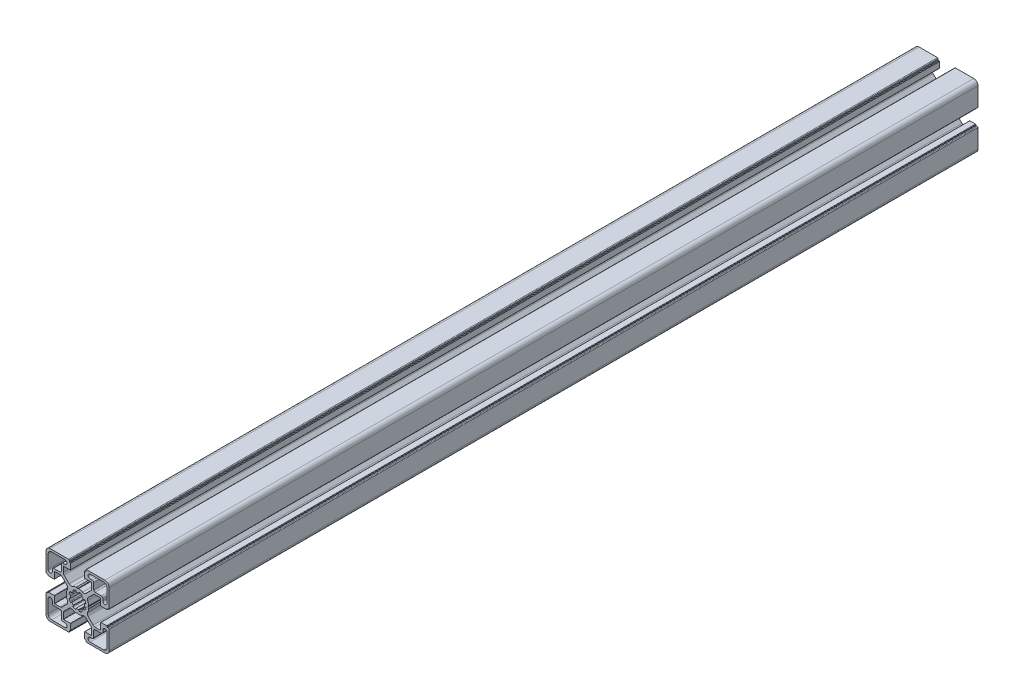
from build123d import *

# Parameters (mm, degrees)
BASE_EXTRUDE_DEPTH = 620


with BuildPart() as part:
    # Sketch1 → Base-Extrude (new body)
    with BuildSketch(Plane.XY):
        with BuildLine():
            Line((7.973976585, 0.792591518), (7.540060475, 0.046829556))
            ThreePointArc((7.540060475, 0.046829556), (7.534295984, 0.023675638), (7.531329941, 0))
            ThreePointArc((7.531329941, 0), (7.534295984, -0.023675638), (7.540060475, -0.046829556))
            Line((7.540060475, -0.046829556), (7.973976585, -0.792591518))
            ThreePointArc((7.973976585, -0.792591518), (7.996666421, -0.851255641), (8.000014047, -0.914065683))
            ThreePointArc((8.000014047, -0.914065683), (7.719730741, -2.298395946), (7.20036345, -3.611859543))
            ThreePointArc((7.20036345, -3.611859543), (7.018857217, -4.793954471), (7.563483933, -5.85869607))
            Line((7.563483933, -5.85869607), (11.129779889, -9.424988026))
            ThreePointArc((11.129779889, -9.424988026), (11.760624613, -9.84650461), (12.504756513, -9.99452154))
            Line((12.504756513, -9.99452154), (16.316902451, -9.99452154))
            ThreePointArc((16.316902451, -9.99452154), (16.458324055, -9.935942793), (16.516902802, -9.794521189))
            Line((16.516902802, -9.794521189), (16.516902802, -5.200014226))
            ThreePointArc((16.516902802, -5.200014226), (16.575481548, -5.058592621), (16.716903152, -5.000013875))
            Line((16.716903152, -5.000013875), (20.719599904, -5.000013875))
            ThreePointArc((20.719599904, -5.000013875), (20.931731427, -5.087881629), (21.01959918, -5.300013151))
            Line((21.01959918, -5.300013151), (21.01959918, -5.500004099))
            ThreePointArc((21.01959918, -5.500004099), (21.10746708, -5.712135974), (21.319598956, -5.800003874))
            Line((21.319598956, -5.800003874), (21.999979514, -5.800003874))
            ThreePointArc((21.999979514, -5.800003874), (22.35353264, -5.946450374), (22.49997914, -6.300003501))
            Line((22.49997914, -6.300003501), (22.49997914, -19.500016116))
            ThreePointArc((22.49997914, -19.500016116), (21.62130014, -21.621334875), (19.499981381, -22.500013875))
            Line((19.499981381, -22.500013875), (6.375709012, -22.500013875))
            ThreePointArc((6.375709012, -22.500013875), (6.022155886, -22.353567375), (5.875709386, -22.000014249))
            Line((5.875709386, -22.000014249), (5.875709386, -21.30001315))
            ThreePointArc((5.875709386, -21.30001315), (5.787841632, -21.087881628), (5.57571011, -21.000013874))
            Line((5.57571011, -21.000013874), (5.299998776, -21.000013874))
            ThreePointArc((5.299998776, -21.000013874), (5.087867607, -20.912146267), (5, -20.700015099))
            Line((5, -20.700015099), (5, -16.666812433))
            ThreePointArc((5, -16.666812433), (5.058578893, -16.525390475), (5.200000851, -16.466811582))
            Line((5.200000851, -16.466811582), (9.905385218, -16.466811582))
            ThreePointArc((9.905385218, -16.466811582), (10.046806822, -16.408232835), (10.105385569, -16.266811231))
            Line((10.105385569, -16.266811231), (10.105385569, -12.471582956))
            ThreePointArc((10.105385569, -12.471582956), (9.953144588, -11.706215861), (9.519598955, -11.057368968))
            Line((9.519598955, -11.057368968), (5.944897989, -7.482668002))
            ThreePointArc((5.944897989, -7.482668002), (4.854601835, -6.967833724), (3.666499237, -7.173289937))
            ThreePointArc((3.666499237, -7.173289937), (2.309136684, -7.713848333), (0.876396038, -8.000013875))
            ThreePointArc((0.876396038, -8.000013875), (0.81356491, -7.997088573), (0.754749577, -7.974793627))
            Line((0.754749577, -7.974793627), (0.11262846, -7.606936933))
            ThreePointArc((0.11262846, -7.606936933), (0.062963903, -7.559088739), (0, -7.530953975))
            ThreePointArc((0, -7.530953975), (-0.062963903, -7.559088739), (-0.11262846, -7.606936933))
            Line((-0.11262846, -7.606936933), (-0.754749577, -7.974793627))
            ThreePointArc((-0.754749577, -7.974793627), (-0.81356491, -7.997088573), (-0.876396038, -8.000013875))
            ThreePointArc((-0.876396038, -8.000013875), (-2.309136684, -7.713848333), (-3.666499237, -7.173289937))
            ThreePointArc((-3.666499237, -7.173289937), (-4.854601835, -6.967833724), (-5.944897989, -7.482668002))
            Line((-5.944897989, -7.482668002), (-9.519598955, -11.057368968))
            ThreePointArc((-9.519598955, -11.057368968), (-9.953144588, -11.706215861), (-10.105385569, -12.471582956))
            Line((-10.105385569, -12.471582956), (-10.105385569, -16.266811231))
            ThreePointArc((-10.105385569, -16.266811231), (-10.046806822, -16.408232835), (-9.905385218, -16.466811582))
            Line((-9.905385218, -16.466811582), (-5.200000851, -16.466811582))
            ThreePointArc((-5.200000851, -16.466811582), (-5.058578893, -16.525390475), (-5, -16.666812433))
            Line((-5, -16.666812433), (-5, -20.700015099))
            ThreePointArc((-5, -20.700015099), (-5.087867607, -20.912146267), (-5.299998776, -21.000013874))
            Line((-5.299998776, -21.000013874), (-5.57571011, -21.000013874))
            ThreePointArc((-5.57571011, -21.000013874), (-5.787841632, -21.087881628), (-5.875709386, -21.30001315))
            Line((-5.875709386, -21.30001315), (-5.875709386, -22.000014249))
            ThreePointArc((-5.875709386, -22.000014249), (-6.022155886, -22.353567375), (-6.375709012, -22.500013875))
            Line((-6.375709012, -22.500013875), (-19.499981381, -22.500013875))
            ThreePointArc((-19.499981381, -22.500013875), (-21.62130014, -21.621334875), (-22.49997914, -19.500016116))
            Line((-22.49997914, -19.500016116), (-22.49997914, -6.300003501))
            ThreePointArc((-22.49997914, -6.300003501), (-22.35353264, -5.946450374), (-21.999979514, -5.800003874))
            Line((-21.999979514, -5.800003874), (-21.319598956, -5.800003874))
            ThreePointArc((-21.319598956, -5.800003874), (-21.10746708, -5.712135974), (-21.01959918, -5.500004099))
            Line((-21.01959918, -5.500004099), (-21.01959918, -5.300013151))
            ThreePointArc((-21.01959918, -5.300013151), (-20.931731427, -5.087881629), (-20.719599904, -5.000013875))
            Line((-20.719599904, -5.000013875), (-16.716903152, -5.000013875))
            ThreePointArc((-16.716903152, -5.000013875), (-16.575481548, -5.058592621), (-16.516902802, -5.200014226))
            Line((-16.516902802, -5.200014226), (-16.516902802, -9.794521189))
            ThreePointArc((-16.516902802, -9.794521189), (-16.458324055, -9.935942793), (-16.316902451, -9.99452154))
            Line((-16.316902451, -9.99452154), (-12.504756513, -9.99452154))
            ThreePointArc((-12.504756513, -9.99452154), (-11.760624613, -9.84650461), (-11.129779889, -9.424988026))
            Line((-11.129779889, -9.424988026), (-7.563483933, -5.85869607))
            ThreePointArc((-7.563483933, -5.85869607), (-7.018857217, -4.793954471), (-7.20036345, -3.611859543))
            ThreePointArc((-7.20036345, -3.611859543), (-7.719730741, -2.298395946), (-8.000014047, -0.914065683))
            ThreePointArc((-8.000014047, -0.914065683), (-7.996666421, -0.851255641), (-7.973976585, -0.792591518))
            Line((-7.973976585, -0.792591518), (-7.540060475, -0.046829556))
            ThreePointArc((-7.540060475, -0.046829556), (-7.534295984, -0.023675638), (-7.531329941, 0))
            ThreePointArc((-7.531329941, 0), (-7.534295984, 0.023675638), (-7.540060475, 0.046829556))
            Line((-7.540060475, 0.046829556), (-7.973976585, 0.792591518))
            ThreePointArc((-7.973976585, 0.792591518), (-7.996666421, 0.851255641), (-8.000014047, 0.914065683))
            ThreePointArc((-8.000014047, 0.914065683), (-7.719730741, 2.298395946), (-7.20036345, 3.611859543))
            ThreePointArc((-7.20036345, 3.611859543), (-7.018857217, 4.793954471), (-7.563483933, 5.85869607))
            Line((-7.563483933, 5.85869607), (-11.129779889, 9.424988026))
            ThreePointArc((-11.129779889, 9.424988026), (-11.760624613, 9.84650461), (-12.504756513, 9.99452154))
            Line((-12.504756513, 9.99452154), (-16.316902451, 9.99452154))
            ThreePointArc((-16.316902451, 9.99452154), (-16.458324055, 9.935942793), (-16.516902802, 9.794521189))
            Line((-16.516902802, 9.794521189), (-16.516902802, 5.200014226))
            ThreePointArc((-16.516902802, 5.200014226), (-16.575481548, 5.058592621), (-16.716903152, 5.000013875))
            Line((-16.716903152, 5.000013875), (-20.719599904, 5.000013875))
            ThreePointArc((-20.719599904, 5.000013875), (-20.931731427, 5.087881629), (-21.01959918, 5.300013151))
            Line((-21.01959918, 5.300013151), (-21.01959918, 5.500004099))
            ThreePointArc((-21.01959918, 5.500004099), (-21.10746708, 5.712135974), (-21.319598956, 5.800003874))
            Line((-21.319598956, 5.800003874), (-21.999979514, 5.800003874))
            ThreePointArc((-21.999979514, 5.800003874), (-22.35353264, 5.946450374), (-22.49997914, 6.300003501))
            Line((-22.49997914, 6.300003501), (-22.49997914, 19.500016116))
            ThreePointArc((-22.49997914, 19.500016116), (-21.62130014, 21.621334875), (-19.499981381, 22.500013875))
            Line((-19.499981381, 22.500013875), (-6.375709012, 22.500013875))
            ThreePointArc((-6.375709012, 22.500013875), (-6.022155886, 22.353567375), (-5.875709386, 22.000014249))
            Line((-5.875709386, 22.000014249), (-5.875709386, 21.30001315))
            ThreePointArc((-5.875709386, 21.30001315), (-5.787841632, 21.087881628), (-5.57571011, 21.000013874))
            Line((-5.57571011, 21.000013874), (-5.299998776, 21.000013874))
            ThreePointArc((-5.299998776, 21.000013874), (-5.087867607, 20.912146267), (-5, 20.700015099))
            Line((-5, 20.700015099), (-5, 16.666812433))
            ThreePointArc((-5, 16.666812433), (-5.058578893, 16.525390475), (-5.200000851, 16.466811582))
            Line((-5.200000851, 16.466811582), (-9.905385218, 16.466811582))
            ThreePointArc((-9.905385218, 16.466811582), (-10.046806822, 16.408232835), (-10.105385569, 16.266811231))
            Line((-10.105385569, 16.266811231), (-10.105385569, 12.471582956))
            ThreePointArc((-10.105385569, 12.471582956), (-9.953144588, 11.706215861), (-9.519598955, 11.057368968))
            Line((-9.519598955, 11.057368968), (-5.944897989, 7.482668002))
            ThreePointArc((-5.944897989, 7.482668002), (-4.854601835, 6.967833724), (-3.666499237, 7.173289937))
            ThreePointArc((-3.666499237, 7.173289937), (-2.309136684, 7.713848333), (-0.876396038, 8.000013875))
            ThreePointArc((-0.876396038, 8.000013875), (-0.81356491, 7.997088573), (-0.754749577, 7.974793627))
            Line((-0.754749577, 7.974793627), (-0.11262846, 7.606936933))
            ThreePointArc((-0.11262846, 7.606936933), (-0.062963903, 7.559088739), (0, 7.530953975))
            ThreePointArc((0, 7.530953975), (0.062963903, 7.559088739), (0.11262846, 7.606936933))
            Line((0.11262846, 7.606936933), (0.754749577, 7.974793627))
            ThreePointArc((0.754749577, 7.974793627), (0.81356491, 7.997088573), (0.876396038, 8.000013875))
            ThreePointArc((0.876396038, 8.000013875), (2.309136684, 7.713848333), (3.666499237, 7.173289937))
            ThreePointArc((3.666499237, 7.173289937), (4.854601835, 6.967833724), (5.944897989, 7.482668002))
            Line((5.944897989, 7.482668002), (9.519598955, 11.057368968))
            ThreePointArc((9.519598955, 11.057368968), (9.953144588, 11.706215861), (10.105385569, 12.471582956))
            Line((10.105385569, 12.471582956), (10.105385569, 16.266811231))
            ThreePointArc((10.105385569, 16.266811231), (10.046806822, 16.408232835), (9.905385218, 16.466811582))
            Line((9.905385218, 16.466811582), (5.200000851, 16.466811582))
            ThreePointArc((5.200000851, 16.466811582), (5.058578893, 16.525390475), (5, 16.666812433))
            Line((5, 16.666812433), (5, 20.700015099))
            ThreePointArc((5, 20.700015099), (5.087867607, 20.912146267), (5.299998776, 21.000013874))
            Line((5.299998776, 21.000013874), (5.57571011, 21.000013874))
            ThreePointArc((5.57571011, 21.000013874), (5.787841632, 21.087881628), (5.875709386, 21.30001315))
            Line((5.875709386, 21.30001315), (5.875709386, 22.000014249))
            ThreePointArc((5.875709386, 22.000014249), (6.022155886, 22.353567375), (6.375709012, 22.500013875))
            Line((6.375709012, 22.500013875), (19.499981381, 22.500013875))
            ThreePointArc((19.499981381, 22.500013875), (21.62130014, 21.621334875), (22.49997914, 19.500016116))
            Line((22.49997914, 19.500016116), (22.49997914, 6.300003501))
            ThreePointArc((22.49997914, 6.300003501), (22.35353264, 5.946450374), (21.999979514, 5.800003874))
            Line((21.999979514, 5.800003874), (21.319598956, 5.800003874))
            ThreePointArc((21.319598956, 5.800003874), (21.10746708, 5.712135974), (21.01959918, 5.500004099))
            Line((21.01959918, 5.500004099), (21.01959918, 5.300013151))
            ThreePointArc((21.01959918, 5.300013151), (20.931731427, 5.087881629), (20.719599904, 5.000013875))
            Line((20.719599904, 5.000013875), (16.716903152, 5.000013875))
            ThreePointArc((16.716903152, 5.000013875), (16.575481548, 5.058592621), (16.516902802, 5.200014226))
            Line((16.516902802, 5.200014226), (16.516902802, 9.794521189))
            ThreePointArc((16.516902802, 9.794521189), (16.458324055, 9.935942793), (16.316902451, 9.99452154))
            Line((16.316902451, 9.99452154), (12.504756513, 9.99452154))
            ThreePointArc((12.504756513, 9.99452154), (11.760624613, 9.84650461), (11.129779889, 9.424988026))
            Line((11.129779889, 9.424988026), (7.563483933, 5.85869607))
            ThreePointArc((7.563483933, 5.85869607), (7.018857217, 4.793954471), (7.20036345, 3.611859543))
            ThreePointArc((7.20036345, 3.611859543), (7.719730741, 2.298395946), (8.000014047, 0.914065683))
            ThreePointArc((8.000014047, 0.914065683), (7.996666421, 0.851255641), (7.973976585, 0.792591518))
        make_face()
        with BuildLine():
            Line((10.549978885, 18.000013874), (8.999979138, 18.000013874))
            ThreePointArc((8.999979138, 18.000013874), (7.499979138, 19.500013874), (8.999979138, 21.000013874))
            Line((8.999979138, 21.000013874), (18.499981006, 21.000013874))
            ThreePointArc((18.499981006, 21.000013874), (20.267746638, 20.267781374), (20.999979138, 18.500015742))
            Line((20.999979138, 18.500015742), (20.999979138, 9.000204874))
            ThreePointArc((20.999979138, 9.000204874), (19.499979138, 7.500204874), (17.999979138, 9.000204874))
            Line((17.999979138, 9.000204874), (17.999979138, 10.550013621))
            ThreePointArc((17.999979138, 10.550013621), (17.707086138, 11.257119874), (16.999979885, 11.550012874))
            Line((16.999979885, 11.550012874), (12.549977391, 11.550012874))
            ThreePointArc((12.549977391, 11.550012874), (11.842871138, 11.842905874), (11.549978138, 12.550012127))
            Line((11.549978138, 12.550012127), (11.549978138, 17.000014621))
            ThreePointArc((11.549978138, 17.000014621), (11.257085138, 17.707120874), (10.549978885, 18.000013874))
        make_face(mode=Mode.SUBTRACT)
        with BuildLine():
            Line((-0.867388737, 4.924188946), (-0.96752168, 5.481112935))
            ThreePointArc((-0.96752168, 5.481112935), (-1.187855719, 5.829589164), (-1.595071417, 5.894072848))
            ThreePointArc((-1.595071417, 5.894072848), (-2.338895973, 5.643477696), (-3.04438497, 5.299445466))
            ThreePointArc((-3.04438497, 5.299445466), (-3.284615367, 4.964275075), (-3.191311906, 4.562598216))
            Line((-3.191311906, 4.562598216), (-2.864000421, 4.09847552))
            ThreePointArc((-2.864000421, 4.09847552), (-3.53013295, 3.540926624), (-4.08971289, 2.876499344))
            Line((-4.08971289, 2.876499344), (-4.566777651, 3.208162503))
            ThreePointArc((-4.566777651, 3.208162503), (-4.968960845, 3.298770682), (-5.302497889, 3.056460542))
            ThreePointArc((-5.302497889, 3.056460542), (-5.651259984, 2.353310881), (-5.906847665, 1.611199444))
            ThreePointArc((-5.906847665, 1.611199444), (-5.839752063, 1.204293023), (-5.489730697, 0.98621116))
            Line((-5.489730697, 0.98621116), (-4.920545766, 0.887822825))
            ThreePointArc((-4.920545766, 0.887822825), (-4.980096828, 0.445685524), (-5, 0))
            ThreePointArc((-5, 0), (-4.980096828, -0.445685524), (-4.920545766, -0.887822825))
            Line((-4.920545766, -0.887822825), (-5.489730697, -0.98621116))
            ThreePointArc((-5.489730697, -0.98621116), (-5.839752063, -1.204293023), (-5.906847665, -1.611199444))
            ThreePointArc((-5.906847665, -1.611199444), (-5.651259984, -2.353310881), (-5.302497889, -3.056460542))
            ThreePointArc((-5.302497889, -3.056460542), (-4.968960845, -3.298770682), (-4.566777651, -3.208162503))
            Line((-4.566777651, -3.208162503), (-4.08971289, -2.876499344))
            ThreePointArc((-4.08971289, -2.876499344), (-3.53013295, -3.540926624), (-2.864000421, -4.09847552))
            Line((-2.864000421, -4.09847552), (-3.191311906, -4.562598216))
            ThreePointArc((-3.191311906, -4.562598216), (-3.284615367, -4.964275075), (-3.04438497, -5.299445466))
            ThreePointArc((-3.04438497, -5.299445466), (-2.338895973, -5.643477696), (-1.595071417, -5.894072848))
            ThreePointArc((-1.595071417, -5.894072848), (-1.187855719, -5.829589164), (-0.96752168, -5.481112935))
            Line((-0.96752168, -5.481112935), (-0.867388737, -4.924188946))
            ThreePointArc((-0.867388737, -4.924188946), (0, -5), (0.867388737, -4.924188946))
            Line((0.867388737, -4.924188946), (0.96752168, -5.481112935))
            ThreePointArc((0.96752168, -5.481112935), (1.187855719, -5.829589164), (1.595071417, -5.894072848))
            ThreePointArc((1.595071417, -5.894072848), (2.338895973, -5.643477696), (3.04438497, -5.299445466))
            ThreePointArc((3.04438497, -5.299445466), (3.284615367, -4.964275075), (3.191311906, -4.562598216))
            Line((3.191311906, -4.562598216), (2.864000421, -4.09847552))
            ThreePointArc((2.864000421, -4.09847552), (3.53013295, -3.540926624), (4.08971289, -2.876499344))
            Line((4.08971289, -2.876499344), (4.566777651, -3.208162503))
            ThreePointArc((4.566777651, -3.208162503), (4.968960845, -3.298770682), (5.302497889, -3.056460542))
            ThreePointArc((5.302497889, -3.056460542), (5.651259984, -2.353310881), (5.906847665, -1.611199444))
            ThreePointArc((5.906847665, -1.611199444), (5.839752063, -1.204293023), (5.489730697, -0.98621116))
            Line((5.489730697, -0.98621116), (4.920545766, -0.887822825))
            ThreePointArc((4.920545766, -0.887822825), (4.980096828, -0.445685524), (5, 0))
            ThreePointArc((5, 0), (4.980096828, 0.445685524), (4.920545766, 0.887822825))
            Line((4.920545766, 0.887822825), (5.489730697, 0.98621116))
            ThreePointArc((5.489730697, 0.98621116), (5.839752063, 1.204293023), (5.906847665, 1.611199444))
            ThreePointArc((5.906847665, 1.611199444), (5.651259984, 2.353310881), (5.302497889, 3.056460542))
            ThreePointArc((5.302497889, 3.056460542), (4.968960845, 3.298770682), (4.566777651, 3.208162503))
            Line((4.566777651, 3.208162503), (4.08971289, 2.876499344))
            ThreePointArc((4.08971289, 2.876499344), (3.53013295, 3.540926624), (2.864000421, 4.09847552))
            Line((2.864000421, 4.09847552), (3.191311906, 4.562598216))
            ThreePointArc((3.191311906, 4.562598216), (3.284615367, 4.964275075), (3.04438497, 5.299445466))
            ThreePointArc((3.04438497, 5.299445466), (2.338895973, 5.643477696), (1.595071417, 5.894072848))
            ThreePointArc((1.595071417, 5.894072848), (1.187855719, 5.829589164), (0.96752168, 5.481112935))
            Line((0.96752168, 5.481112935), (0.867388737, 4.924188946))
            ThreePointArc((0.867388737, 4.924188946), (0, 5), (-0.867388737, 4.924188946))
        make_face(mode=Mode.SUBTRACT)
        with BuildLine():
            Line((-10.549978885, -18.000013874), (-8.999979138, -18.000013874))
            ThreePointArc((-8.999979138, -18.000013874), (-7.499979138, -19.500013874), (-8.999979138, -21.000013874))
            Line((-8.999979138, -21.000013874), (-18.499981006, -21.000013874))
            ThreePointArc((-18.499981006, -21.000013874), (-20.267746638, -20.267781374), (-20.999979138, -18.500015742))
            Line((-20.999979138, -18.500015742), (-20.999979138, -9.000204874))
            ThreePointArc((-20.999979138, -9.000204874), (-19.499979138, -7.500204874), (-17.999979138, -9.000204874))
            Line((-17.999979138, -9.000204874), (-17.999979138, -10.550013621))
            ThreePointArc((-17.999979138, -10.550013621), (-17.707086138, -11.257119874), (-16.999979885, -11.550012874))
            Line((-16.999979885, -11.550012874), (-12.549977391, -11.550012874))
            ThreePointArc((-12.549977391, -11.550012874), (-11.842871138, -11.842905874), (-11.549978138, -12.550012127))
            Line((-11.549978138, -12.550012127), (-11.549978138, -17.000014621))
            ThreePointArc((-11.549978138, -17.000014621), (-11.257085138, -17.707120874), (-10.549978885, -18.000013874))
        make_face(mode=Mode.SUBTRACT)
        with BuildLine():
            Line((-11.549978138, 12.550012127), (-11.549978138, 17.000014621))
            ThreePointArc((-11.549978138, 17.000014621), (-11.257085138, 17.707120874), (-10.549978885, 18.000013874))
            Line((-10.549978885, 18.000013874), (-8.999979138, 18.000013874))
            ThreePointArc((-8.999979138, 18.000013874), (-7.499979138, 19.500013874), (-8.999979138, 21.000013874))
            Line((-8.999979138, 21.000013874), (-18.499981006, 21.000013874))
            ThreePointArc((-18.499981006, 21.000013874), (-20.267746638, 20.267781374), (-20.999979138, 18.500015742))
            Line((-20.999979138, 18.500015742), (-20.999979138, 9.000204874))
            ThreePointArc((-20.999979138, 9.000204874), (-19.499979138, 7.500204874), (-17.999979138, 9.000204874))
            Line((-17.999979138, 9.000204874), (-17.999979138, 10.550013621))
            ThreePointArc((-17.999979138, 10.550013621), (-17.707086138, 11.257119874), (-16.999979885, 11.550012874))
            Line((-16.999979885, 11.550012874), (-12.549977391, 11.550012874))
            ThreePointArc((-12.549977391, 11.550012874), (-11.842871138, 11.842905874), (-11.549978138, 12.550012127))
        make_face(mode=Mode.SUBTRACT)
        with BuildLine():
            Line((11.549978138, -12.550012127), (11.549978138, -17.000014621))
            ThreePointArc((11.549978138, -17.000014621), (11.257085138, -17.707120874), (10.549978885, -18.000013874))
            Line((10.549978885, -18.000013874), (8.999979138, -18.000013874))
            ThreePointArc((8.999979138, -18.000013874), (7.499979138, -19.500013874), (8.999979138, -21.000013874))
            Line((8.999979138, -21.000013874), (18.499981006, -21.000013874))
            ThreePointArc((18.499981006, -21.000013874), (20.267746638, -20.267781374), (20.999979138, -18.500015742))
            Line((20.999979138, -18.500015742), (20.999979138, -9.000204874))
            ThreePointArc((20.999979138, -9.000204874), (19.499979138, -7.500204874), (17.999979138, -9.000204874))
            Line((17.999979138, -9.000204874), (17.999979138, -10.550013621))
            ThreePointArc((17.999979138, -10.550013621), (17.707086138, -11.257119874), (16.999979885, -11.550012874))
            Line((16.999979885, -11.550012874), (12.549977391, -11.550012874))
            ThreePointArc((12.549977391, -11.550012874), (11.842871138, -11.842905874), (11.549978138, -12.550012127))
        make_face(mode=Mode.SUBTRACT)
    extrude(amount=-BASE_EXTRUDE_DEPTH)


solid = part.part
